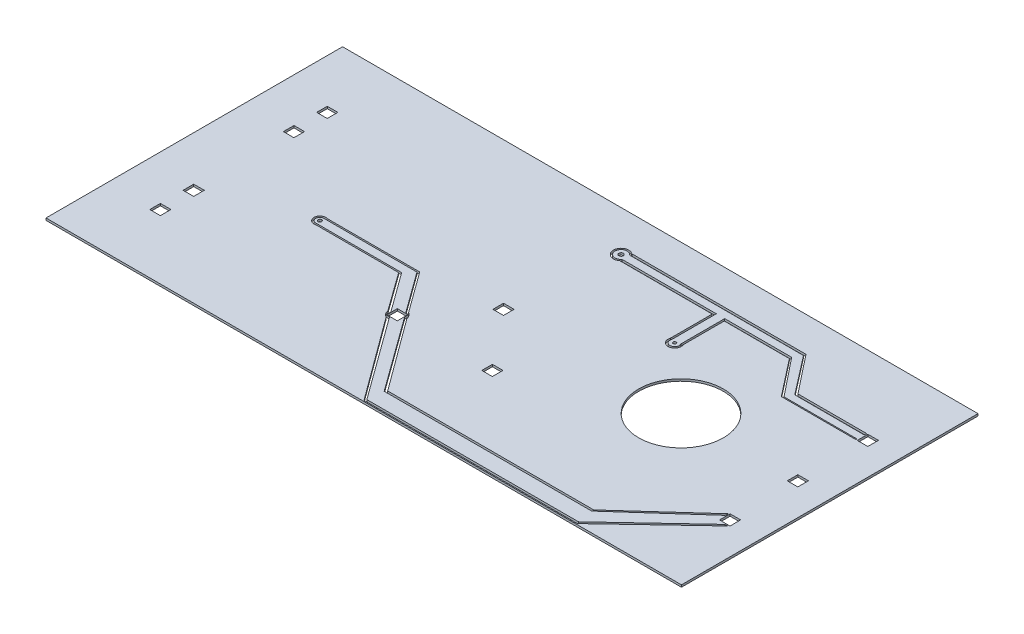
from build123d import *

# Parameters (mm, degrees)
SKETCH1_W           = 30
SKETCH1_H           = 14
SKETCH1_R           = 2
SKETCH1_R_2         = 0.069707308
SKETCH1_R_3         = 0.104510519
SKETCH1_R_4         = 0.084887638
SKETCH1_W_2         = 0.499197809
SKETCH1_H_2         = 0.501456342
SKETCH1_H_3         = 0.501456343
BOSS_EXTRUDE2_DEPTH = 0.1


with BuildPart() as part:
    # Sketch1 → Boss-Extrude2 (new body)
    with BuildSketch(Plane(origin=(0, 0, 0), x_dir=(1, 0, 0), z_dir=(0, 1, 0))):
        with Locations((-15, 7)):
            Rectangle(SKETCH1_W, SKETCH1_H)
        with Locations((-7.020370045, 7)):
            Circle(SKETCH1_R, mode=Mode.SUBTRACT)
        with Locations((-10.054598749, 9.734280097)):
            Circle(SKETCH1_R_2, mode=Mode.SUBTRACT)
        with Locations((-14.930479438, 12.0803142)):
            Circle(SKETCH1_R_3, mode=Mode.SUBTRACT)
        with Locations((-23.42355671, 6.351698017)):
            Circle(SKETCH1_R_4, mode=Mode.SUBTRACT)
        with Locations((-1.506295526, 10.305773891)):
            Rectangle(SKETCH1_W_2, SKETCH1_H_2, mode=Mode.SUBTRACT)
        with Locations((-1.506058557, 7)):
            Rectangle(SKETCH1_W_2, SKETCH1_H_2, mode=Mode.SUBTRACT)
        with BuildLine():
            Line((-4.96101097, 0.046964473), (-1.31173915, 3.49819904))
            Line((-1.31173915, 3.49819904), (-1.443001106, 3.49819904))
            Line((-1.443001106, 3.49819904), (-1.479787132, 3.463649644))
            Line((-1.479787132, 3.463649644), (-5.010670338, 0.147447917))
            Line((-5.010670338, 0.147447917), (-15, 0.147447917))
            Line((-15, 0.147447917), (-17.848796521, 4.06726876))
            Line((-17.848796521, 4.06726876), (-18.014319727, 4.06726876))
            Line((-18.014319727, 4.06726876), (-18.014319727, 4.295021535))
            Line((-18.014319727, 4.295021535), (-19.370357537, 6.160870932))
            Line((-19.370357537, 6.160870932), (-23.42355671, 6.160870932))
            ThreePointArc((-23.42355671, 6.160870932), (-23.614383795, 6.351698017), (-23.42355671, 6.542525102))
            Line((-23.42355671, 6.542525102), (-19.029181473, 6.542525102))
            Line((-19.029181473, 6.542525102), (-17.62839076, 4.612798563))
            Line((-17.62839076, 4.612798563), (-17.487814555, 4.60080418))
            Line((-17.487814555, 4.60080418), (-17.487814555, 4.419141059))
            Line((-17.487814555, 4.419141059), (-14.930479438, 0.896161218))
            Line((-14.930479438, 0.896161218), (-5.135127124, 0.896161218))
            Line((-5.135127124, 0.896161218), (-1.84502254, 3.838045622))
            Line((-1.84502254, 3.838045622), (-1.803361628, 3.8752972))
            Line((-1.803361628, 3.8752972), (-1.803361628, 4.008739354))
            Line((-1.803361628, 4.008739354), (-5.135127124, 0.991932607))
            Line((-5.135127124, 0.991932607), (-14.860958876, 0.991932607))
            Line((-14.860958876, 0.991932607), (-17.363055734, 4.399391562))
            ThreePointArc((-17.363055734, 4.399391562), (-17.431650559, 4.564517202), (-17.566438216, 4.682007688))
            Line((-17.566438216, 4.682007688), (-18.970202274, 6.613029158))
            Line((-18.970202274, 6.613029158), (-23.340033791, 6.613029158))
            ThreePointArc((-23.340033791, 6.613029158), (-23.697910575, 6.351698017), (-23.340033791, 6.090366876))
            Line((-23.340033791, 6.090366876), (-19.441304426, 6.090366876))
            Line((-19.441304426, 6.090366876), (-18.137822853, 4.279075615))
            ThreePointArc((-18.137822853, 4.279075615), (-18.068074192, 4.106519917), (-17.926607711, 3.985575386))
            Line((-17.926607711, 3.985575386), (-15.034486009, 0.046964473))
            Line((-15.034486009, 0.046964473), (-4.96101097, 0.046964473))
        make_face(mode=Mode.SUBTRACT)
        with Locations((-1.506084597, 3.801182197)):
            Rectangle(SKETCH1_W_2, SKETCH1_H_2, mode=Mode.SUBTRACT)
        with BuildLine():
            Line((-7.144578994, 12.364310321), (-6.486189519, 12.364310321))
            Line((-6.486189519, 12.364310321), (-5.05686536, 10.556502062))
            Line((-5.05686536, 10.556502062), (-1.814229317, 10.556502062))
            Line((-1.814229317, 10.556502062), (-1.814229317, 10.443944973))
            Line((-1.814229317, 10.443944973), (-5.093427141, 10.443944973))
            Line((-5.093427141, 10.443944973), (-6.494858626, 12.256144774))
            Line((-6.494858626, 12.256144774), (-14.706243657, 12.256144774))
            ThreePointArc((-14.706243657, 12.256144774), (-15.215432199, 12.0803142), (-14.706243657, 11.904483626))
            Line((-14.706243657, 11.904483626), (-10.258741579, 11.904483626))
            Line((-10.258741579, 11.904483626), (-10.258741579, 9.812957143))
            ThreePointArc((-10.258741579, 9.812957143), (-10.03937832, 9.516030903), (-9.863352573, 9.840531084))
            Line((-9.863352573, 9.840531084), (-9.863352573, 11.904483626))
            Line((-9.863352573, 11.904483626), (-6.700536123, 11.904483626))
            Line((-6.700536123, 11.904483626), (-5.266623049, 10.107938883))
            Line((-5.266623049, 10.107938883), (-1.814229317, 10.107938883))
            Line((-1.814229317, 10.107938883), (-1.814229317, 10.05504572))
            Line((-1.814229317, 10.05504572), (-5.339250668, 10.05504572))
            Line((-5.339250668, 10.05504572), (-6.700536123, 11.796318079))
            Line((-6.700536123, 11.796318079), (-9.774961406, 11.796318079))
            Line((-9.774961406, 11.796318079), (-9.774961406, 9.860139301))
            ThreePointArc((-9.774961406, 9.860139301), (-10.039576048, 9.427992811), (-10.345210476, 9.83216987))
            Line((-10.345210476, 9.83216987), (-10.345210476, 11.796318079))
            Line((-10.345210476, 11.796318079), (-14.706243657, 11.796318079))
            ThreePointArc((-14.706243657, 11.796318079), (-15.29232952, 12.0803142), (-14.706243657, 12.364310321))
            Line((-14.706243657, 12.364310321), (-7.144578994, 12.364310321))
        make_face(mode=Mode.SUBTRACT)
        with Locations((-17.749862376, 4.33551856)):
            Rectangle(SKETCH1_W_2, SKETCH1_H_3, mode=Mode.SUBTRACT)
        with Locations((-13.229055218, 4.302374896)):
            Rectangle(SKETCH1_W_2, SKETCH1_H_2, mode=Mode.SUBTRACT)
        with Locations((-15.465031103, 7.062725803)):
            Rectangle(SKETCH1_W_2, SKETCH1_H_2, mode=Mode.SUBTRACT)
        with Locations((-27.644321584, 3.044426332)):
            Rectangle(SKETCH1_W_2, SKETCH1_H_3, mode=Mode.SUBTRACT)
        with Locations((-27.644321584, 4.617052121)):
            Rectangle(SKETCH1_W_2, SKETCH1_H_2, mode=Mode.SUBTRACT)
        with Locations((-27.677861275, 9.382947879)):
            Rectangle(SKETCH1_W_2, SKETCH1_H_2, mode=Mode.SUBTRACT)
        with Locations((-27.677861275, 10.955573669)):
            Rectangle(SKETCH1_W_2, SKETCH1_H_3, mode=Mode.SUBTRACT)
    extrude(amount=BOSS_EXTRUDE2_DEPTH)


solid = part.part
